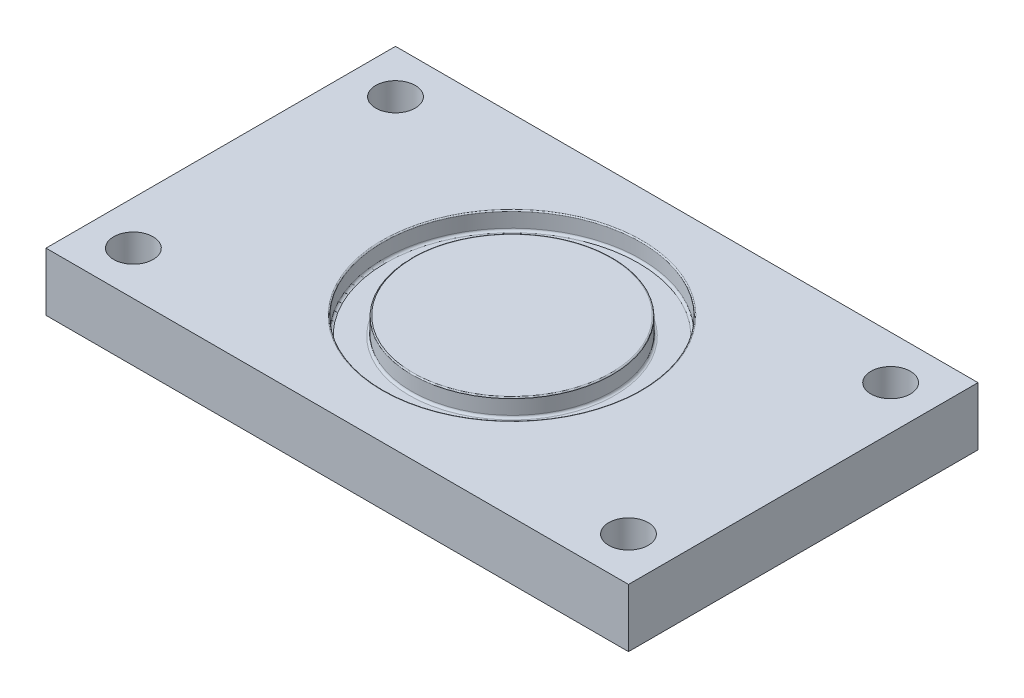
from build123d import *

# Parameters (mm, degrees)
SKETCH1_W             = 63.5
SKETCH1_H             = 38.1
BOSS_EXTRUDE1_DEPTH   = 6.35
SKETCH2_R             = 14.0462
SKETCH2_R_2           = 10.9474
CUT_EXTRUDE1_DEPTH    = 1.9558
F_8_CLEARANCE_HOLE1_D = 4.3053
FILLET1_R             = 0.127
FILLET2_R             = 0.254


with BuildPart() as part:
    # Sketch1 → Boss-Extrude1 (new body)
    with BuildSketch(Plane(origin=(0, 0, 0), x_dir=(1, 0, 0), z_dir=(0, 1, 0))):
        Rectangle(SKETCH1_W, SKETCH1_H)
    extrude(amount=BOSS_EXTRUDE1_DEPTH)

    # Sketch2 → Cut-Extrude1 (cut)
    with BuildSketch(Plane(origin=(0, 6.35, 0), x_dir=(1, 0, 0), z_dir=(0, 1, 0))):
        with Locations(Location((0, 0, 0), (0, 0, 270))):  # turned: the seam where the file's is
            Circle(SKETCH2_R)
        with Locations(Location((0, 0, 0), (0, 0, 270))):  # turned: the seam where the file's is
            Circle(SKETCH2_R_2, mode=Mode.SUBTRACT)
    extrude(amount=-CUT_EXTRUDE1_DEPTH, mode=Mode.SUBTRACT)

    # #8 Clearance Hole1 (through all)
    with Locations(Plane(origin=(0, 0, 0), x_dir=(-1, 0, 0), z_dir=(0, -1, 0))):
        with Locations((26.9875, -14.2875), (-26.9875, -14.2875), (-26.9875, 14.2875), (26.9875, 14.2875)):
            Hole(F_8_CLEARANCE_HOLE1_D / 2)

    # Fillet1
    fillet1_edges = [part.edges().sort_by_distance(p)[0] for p in [
        (0, 6.35, -14.0462),
        (0, 6.35, -10.9474),
    ]]
    fillet(fillet1_edges, radius=FILLET1_R)

    # Fillet2
    fillet2_edges = [part.edges().sort_by_distance(p)[0] for p in [
        (0, 4.3942, -14.0462),
        (0, 4.3942, -10.9474),
    ]]
    fillet(fillet2_edges, radius=FILLET2_R)


solid = part.part
